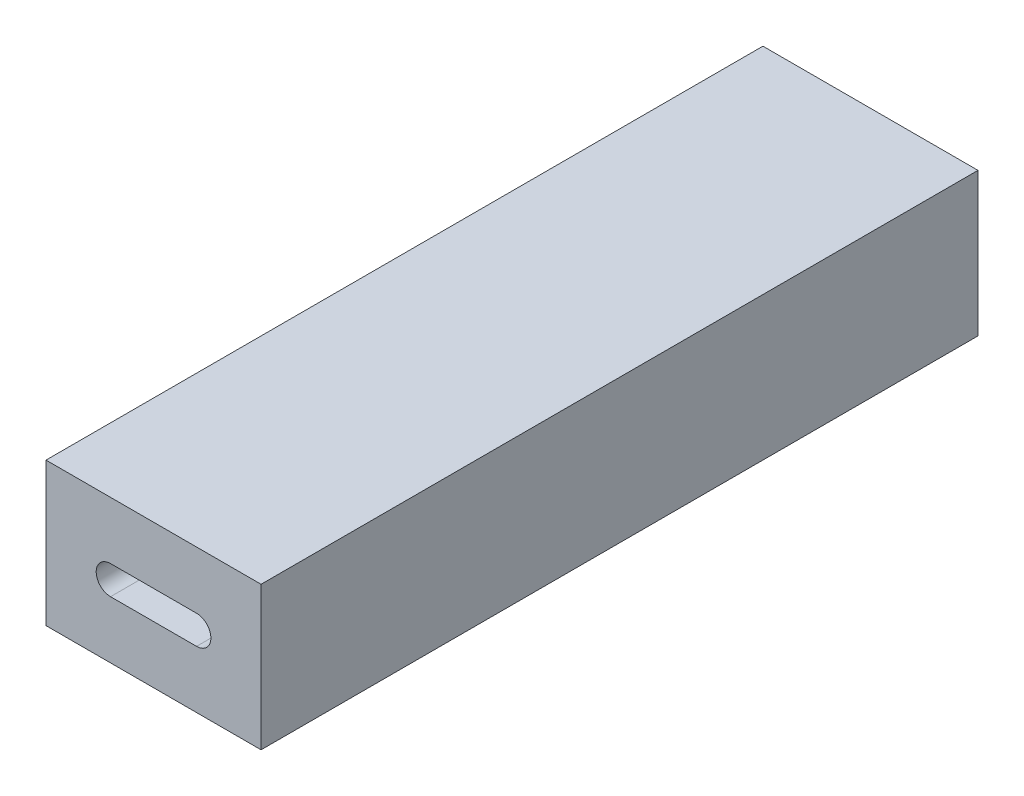
from build123d import *

# Parameters (mm, degrees)
SKETCH1_W           = 15
SKETCH1_H           = 10
BOSS_EXTRUDE1_DEPTH = 50
CUT_EXTRUDE1_DEPTH  = 25
SKETCH3_R           = 2
CUT_EXTRUDE2_DEPTH  = 25


with BuildPart() as part:
    # Sketch1 → Boss-Extrude1 (new body)
    with BuildSketch(Plane.XY):
        Rectangle(SKETCH1_W, SKETCH1_H)
    extrude(amount=BOSS_EXTRUDE1_DEPTH)

    # Sketch2 → Cut-Extrude1 (cut)
    with BuildSketch(Plane.XY.offset(50)):
        with BuildLine():
            Line((-3, 1), (3, 1))
            ThreePointArc((3, 1), (4, 0), (3, -1))
            Line((3, -1), (-3, -1))
            ThreePointArc((-3, -1), (-4, 0), (-3, 1))
        make_face()
    extrude(amount=-CUT_EXTRUDE1_DEPTH, mode=Mode.SUBTRACT)

    # Sketch3 → Cut-Extrude2 (cut)
    with BuildSketch(Plane(origin=(0, 0, 0), x_dir=(-1, 0, 0), z_dir=(0, 0, -1))):
        Circle(SKETCH3_R)
    extrude(amount=-CUT_EXTRUDE2_DEPTH, mode=Mode.SUBTRACT)


solid = part.part
